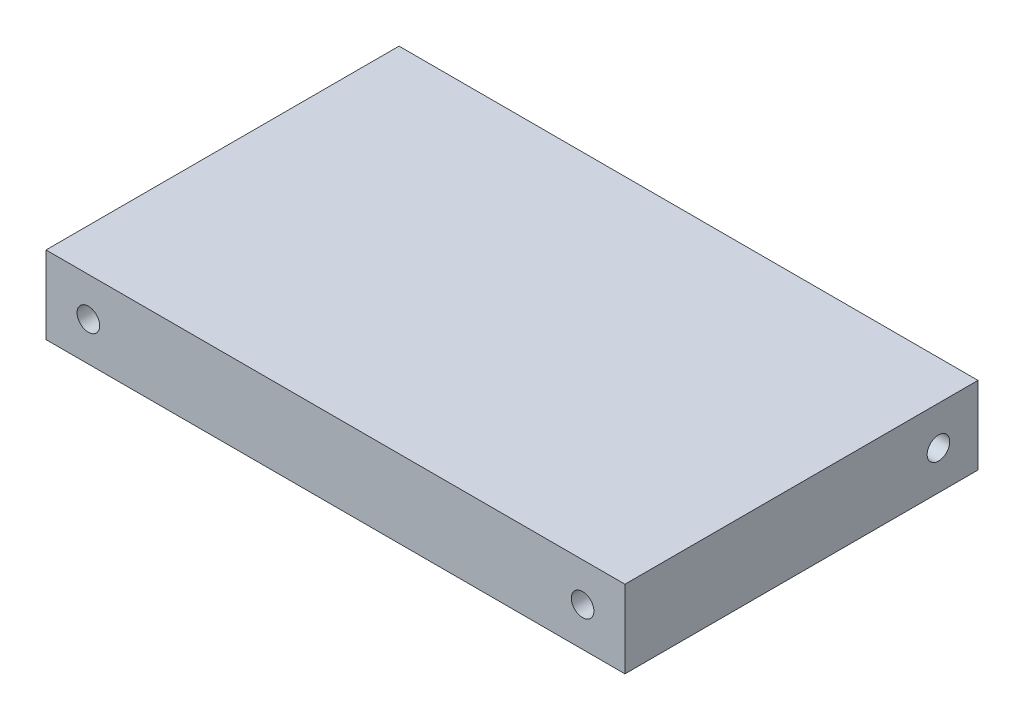
from build123d import *

# Parameters (mm, degrees)
SKETCH1_W           = 82
SKETCH1_H           = 11
BOSS_EXTRUDE1_DEPTH = 50
SKETCH2_R           = 1.6
CUT_EXTRUDE1_DEPTH  = 10
SKETCH3_R           = 1.6
CUT_EXTRUDE2_DEPTH  = 10
SKETCH4_R           = 1.6
CUT_EXTRUDE3_DEPTH  = 15


with BuildPart() as part:
    # Sketch1 → Boss-Extrude1 (new body)
    with BuildSketch(Plane.XY):
        with Locations((-41, 5.5)):
            Rectangle(SKETCH1_W, SKETCH1_H)
    extrude(amount=BOSS_EXTRUDE1_DEPTH)

    # Sketch2 → Cut-Extrude1 (cut)
    with BuildSketch(Plane(origin=(0, 0, 0), x_dir=(0, 0, -1), z_dir=(1, 0, 0))):
        with Locations((-5.6, 5.5)):
            Circle(SKETCH2_R)
    extrude(amount=-CUT_EXTRUDE1_DEPTH, mode=Mode.SUBTRACT)

    # Sketch3 → Cut-Extrude2 (cut)
    with BuildSketch(Plane.ZY.offset(82)):
        with Locations((5.6, 5.5)):
            Circle(SKETCH3_R)
    extrude(amount=-CUT_EXTRUDE2_DEPTH, mode=Mode.SUBTRACT)

    # Sketch4 → Cut-Extrude3 (cut)
    with BuildSketch(Plane.XY.offset(50)):
        with Locations((-76, 5.5)):
            Circle(SKETCH4_R)
        with Locations((-6, 5.5)):
            Circle(SKETCH4_R)
    extrude(amount=-CUT_EXTRUDE3_DEPTH, mode=Mode.SUBTRACT)


solid = part.part
